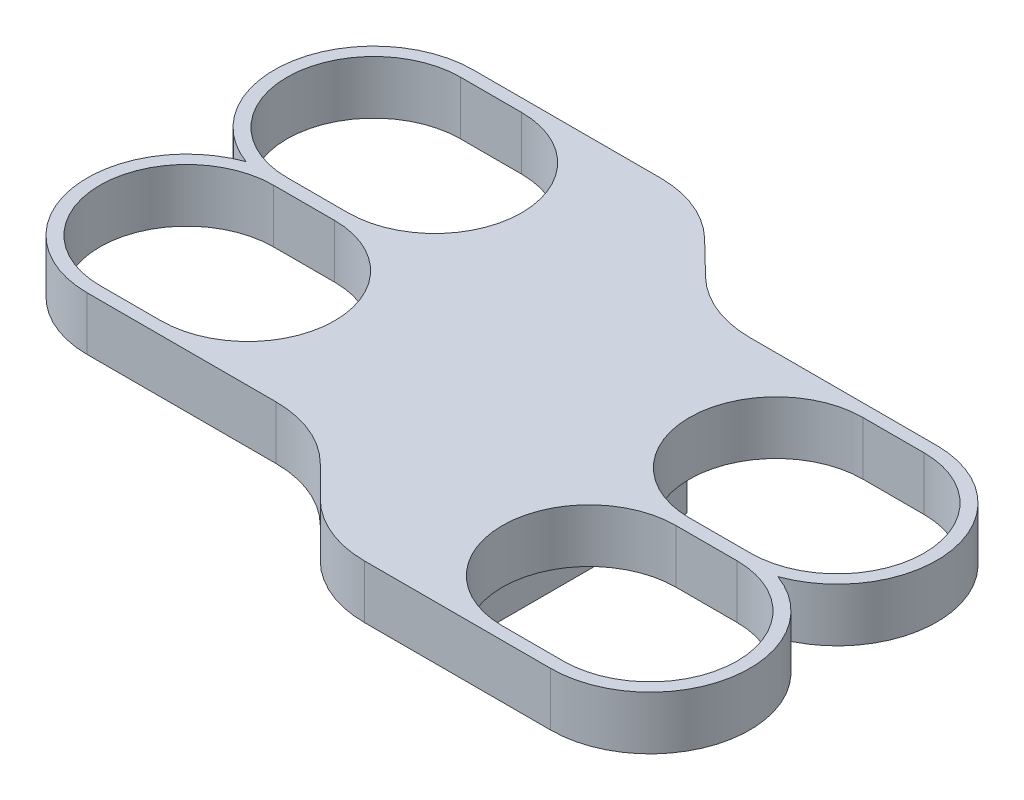
from build123d import *

# Parameters (mm, degrees)
BOSS_EXTRUDE1_DEPTH = 10
BOSS_EXTRUDE3_START = -10
SKETCH2_W           = 25.4
SKETCH2_H           = 40
BOSS_EXTRUDE3_DEPTH = 17
FILLET2_R           = 5


with BuildPart() as part:
    # Sketch1 → Boss-Extrude1 (new body)
    with BuildSketch(Plane(origin=(0, 0, 0), x_dir=(1, 0, 0), z_dir=(0, 1, 0))):
        with BuildLine():
            Line((-40.682943279, 44.876700425), (-52.117056721, 44.876700425))
            ThreePointArc((-52.117056721, 44.876700425), (-70.45991945, 29.48934494), (-58.497022921, 8.75))
            ThreePointArc((-58.497022921, 8.75), (-70.45991945, -11.98934494), (-52.117056721, -27.376700425))
            Line((-52.117056721, -27.376700425), (-40.682943279, -27.376700425))
            Line((-40.682943279, -27.376700425), (-16.783731474, -27.376700425))
            ThreePointArc((-16.783731474, -27.376700425), (-9.130062827, -28.899109774), (-2.64159585, -33.234564801))
            Line((-2.64159585, -33.234564801), (3.142675397, -39.018836048))
            ThreePointArc((3.142675397, -39.018836048), (9.631142374, -43.354291075), (17.284811021, -44.876700425))
            Line((17.284811021, -44.876700425), (40.682943279, -44.876700425))
            Line((40.682943279, -44.876700425), (52.117056721, -44.876700425))
            ThreePointArc((52.117056721, -44.876700425), (70.45991945, -29.48934494), (58.497022921, -8.75))
            ThreePointArc((58.497022921, -8.75), (70.45991945, 11.98934494), (52.117056721, 27.376700425))
            Line((52.117056721, 27.376700425), (40.682943279, 27.376700425))
            Line((40.682943279, 27.376700425), (17.119939677, 27.376700425))
            ThreePointArc((17.119939677, 27.376700425), (9.596852719, 28.845560076), (3.17880165, 33.036384162))
            Line((3.17880165, 33.036384162), (-3.17880165, 39.217016687))
            ThreePointArc((-3.17880165, 39.217016687), (-9.596852719, 43.407840773), (-17.119939677, 44.876700425))
            Line((-17.119939677, 44.876700425), (-40.682943279, 44.876700425))
        make_face()
        with BuildLine():
            Line((-40.682943279, 10), (-52.117056721, 10))
            ThreePointArc((-52.117056721, 10), (-68.367056721, 26.25), (-52.117056721, 42.5))
            Line((-52.117056721, 42.5), (-40.682943279, 42.5))
            ThreePointArc((-40.682943279, 42.5), (-24.432943279, 26.25), (-40.682943279, 10))
        make_face(mode=Mode.SUBTRACT)
        with BuildLine():
            Line((-40.682943279, 7.5), (-52.117056721, 7.5))
            ThreePointArc((-52.117056721, 7.5), (-68.367056721, -8.75), (-52.117056721, -25))
            Line((-52.117056721, -25), (-40.682943279, -25))
            ThreePointArc((-40.682943279, -25), (-24.432943279, -8.75), (-40.682943279, 7.5))
        make_face(mode=Mode.SUBTRACT)
        with BuildLine():
            Line((40.682943279, -10), (52.117056721, -10))
            ThreePointArc((52.117056721, -10), (68.367056721, -26.25), (52.117056721, -42.5))
            Line((52.117056721, -42.5), (40.682943279, -42.5))
            ThreePointArc((40.682943279, -42.5), (24.432943279, -26.25), (40.682943279, -10))
        make_face(mode=Mode.SUBTRACT)
        with BuildLine():
            Line((40.682943279, -7.5), (52.117056721, -7.5))
            ThreePointArc((52.117056721, -7.5), (68.367056721, 8.75), (52.117056721, 25))
            Line((52.117056721, 25), (40.682943279, 25))
            ThreePointArc((40.682943279, 25), (24.432943279, 8.75), (40.682943279, -7.5))
        make_face(mode=Mode.SUBTRACT)
    extrude(amount=BOSS_EXTRUDE1_DEPTH)

    # Sketch2 → Boss-Extrude3 (add)
    with BuildSketch(Plane(origin=(0, 10, 0), x_dir=(1, 0, 0), z_dir=(0, 1, 0)).offset(BOSS_EXTRUDE3_START)):
        Rectangle(SKETCH2_W, SKETCH2_H)
    extrude(amount=-BOSS_EXTRUDE3_DEPTH)

    # Fillet2
    fillet2_edges = [part.edges().sort_by_distance(p)[0] for p in [
        (-12.7, 0, 0),
        (0, 0, 20),
        (12.7, 0, 0),
        (0, 0, -20),
    ]]
    fillet(fillet2_edges, radius=FILLET2_R)


solid = part.part
